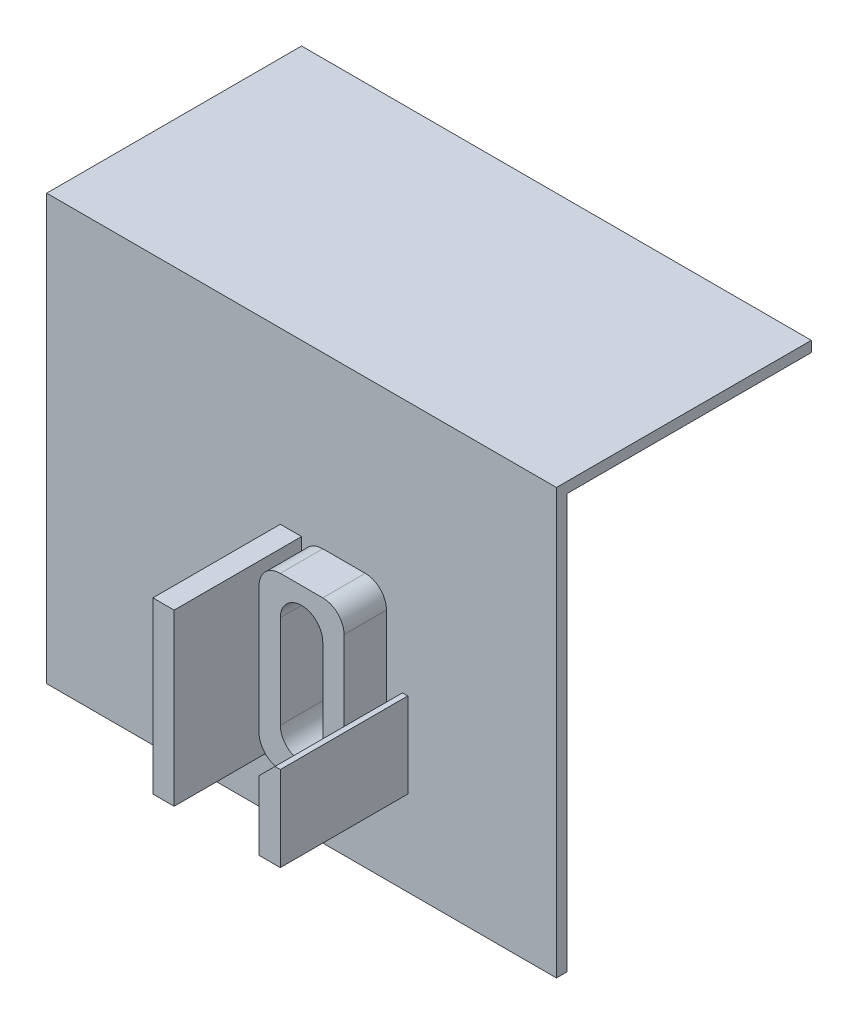
from build123d import *

# Parameters (mm, degrees)
BOSS_EXTRUDE1_DEPTH = 76.2
BOSS_EXTRUDE2_DEPTH = 6.35
CUT_EXTRUDE1_DEPTH  = 6.35
SKETCH4_W           = 3.175
SKETCH4_H           = 25.4
BOSS_EXTRUDE3_DEPTH = 19.05


with BuildPart() as part:
    # Sketch1 → Boss-Extrude1 (new body)
    with BuildSketch(Plane(origin=(0, 0, 0), x_dir=(0, 0, -1), z_dir=(1, 0, 0))):
        Polygon((0, 0), (0, 63.5), (38.1, 63.5), (38.1, 61.9125), (1.5875, 61.9125), (1.5875, 0), align=None)
    extrude(amount=BOSS_EXTRUDE1_DEPTH)

    # Sketch2 → Boss-Extrude2 (add)
    with BuildSketch(Plane.XY):
        with BuildLine():
            Line((41.275, 12.7), (47.625, 12.7))
            ThreePointArc((47.625, 12.7), (49.87006403, 13.62993597), (50.8, 15.875))
            Line((50.8, 15.875), (50.8, 34.925))
            ThreePointArc((50.8, 34.925), (49.87006403, 37.17006403), (47.625, 38.1))
            Line((47.625, 38.1), (41.275, 38.1))
            ThreePointArc((41.275, 38.1), (39.02993597, 37.17006403), (38.1, 34.925))
            Line((38.1, 34.925), (38.1, 15.875))
            ThreePointArc((38.1, 15.875), (39.02993597, 13.62993597), (41.275, 12.7))
        make_face()
        with BuildLine():
            Line((41.275, 32.358201644), (41.275, 18.441798356))
            ThreePointArc((41.275, 18.441798356), (44.45, 15.266798356), (47.625, 18.441798356))
            Line((47.625, 18.441798356), (47.625, 32.358201644))
            ThreePointArc((47.625, 32.358201644), (44.45, 35.533201644), (41.275, 32.358201644))
        make_face(mode=Mode.SUBTRACT)
    extrude(amount=BOSS_EXTRUDE2_DEPTH)

    # Sketch3 → Cut-Extrude1 (cut)
    with BuildSketch(Plane.XY):
        with BuildLine():
            Line((47.625, 18.441798356), (47.625, 32.358201644))
            ThreePointArc((47.625, 32.358201644), (44.45, 35.533201644), (41.275, 32.358201644))
            Line((41.275, 32.358201644), (41.275, 18.441798356))
            ThreePointArc((41.275, 18.441798356), (44.45, 15.266798356), (47.625, 18.441798356))
        make_face()
    extrude(amount=-CUT_EXTRUDE1_DEPTH, mode=Mode.SUBTRACT)

    # Sketch4 → Boss-Extrude3 (add)
    with BuildSketch(Plane.XY):
        Polygon((50.8, 12.7), (50.8, 23.01875), (53.18125, 25.4), (53.975, 25.4), (53.975, 12.7), align=None)
        with Locations((36.5125, 25.4)):
            Rectangle(SKETCH4_W, SKETCH4_H)
    extrude(amount=BOSS_EXTRUDE3_DEPTH)


solid = part.part
